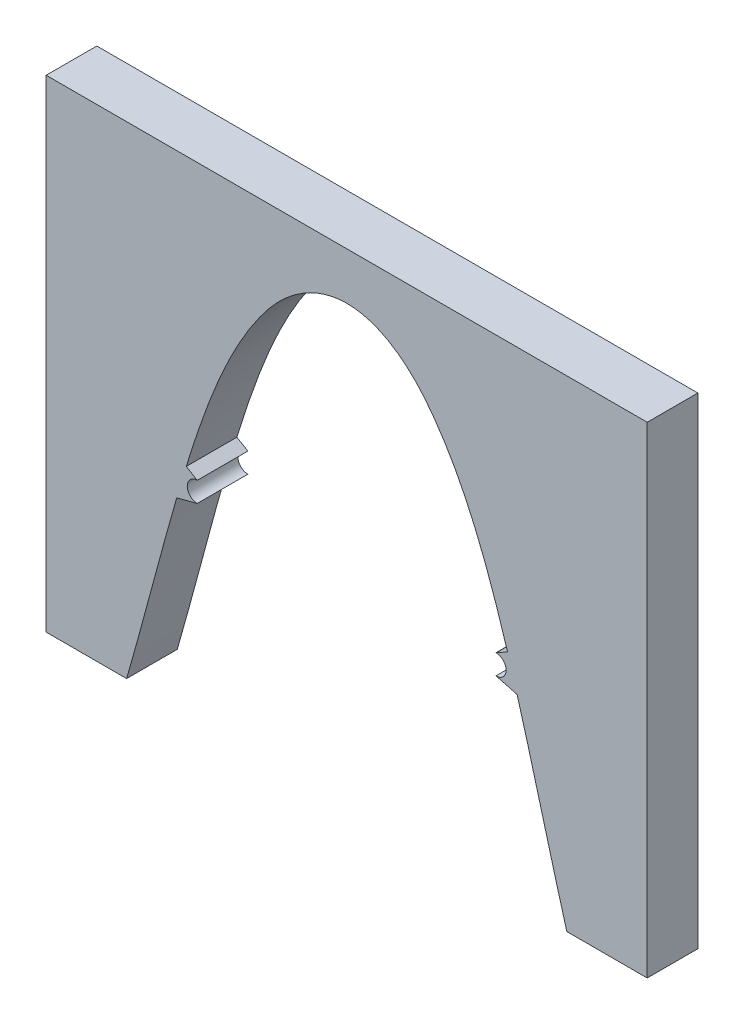
from build123d import *

# Parameters (mm, degrees)
BOSS_EXTRUDE1_DEPTH = 48.006


with BuildPart() as part:
    # Sketch1 → Boss-Extrude1 (new body)
    with BuildSketch(Plane.XY):
        with BuildLine():
            Line((-225.447809165, -199.728491805), (-301.738433253, -199.728491805))
            Line((-301.738433253, -199.728491805), (-301.738433253, 257.593482095))
            Line((-301.738433253, 257.593482095), (268.17262038, 257.593482095))
            Line((268.17262038, 257.593482095), (268.17262038, -198.775273895))
            Line((268.17262038, -198.775273895), (191.97262038, -198.775273895))
            add(Edge.make_bspline(
                [(191.97262038, -198.775273895), (176.395114076, -144.717919568), (162.628696684, -89.958041402), (146.381833133, -33.125288105), (145.596508442, -30.394873062), (144.806285869, -27.666357915)],
                knots=[-0.175685276, -0.175685276, -0.175685276, -0.175685276, 0.0625, 0.0625, 0.074528353, 0.074528353, 0.074528353, 0.074528353], degree=3))
            Line((144.806285869, -27.666357915), (124.993066201, -22.397165799))
            ThreePointArc((124.993066201, -22.397165799), (124.864606243, -22.396297326), (124.73616977, -22.393692067))
            ThreePointArc((124.73616977, -22.393692067), (134.400862059, -12.896168334), (124.73616977, -3.398644601))
            ThreePointArc((124.73616977, -3.398644601), (124.864606243, -3.396039342), (124.993066201, -3.395170869))
            Line((124.993066201, -3.395170869), (135.691858465, 2.892490258))
            add(Edge.make_bspline(
                [(135.691858465, 2.892490258), (135.314696992, 4.116620429), (134.936080504, 5.340186197), (132.368798727, 13.599894472), (130.130676764, 20.616852667), (125.524522045, 34.600376485), (123.157499627, 41.56733402), (115.797446194, 62.367745534), (110.548077039, 76.101765603), (101.84386822, 96.380777425), (98.803508299, 103.086546431), (92.37760033, 116.364185503), (88.991984333, 122.93602921), (81.793802186, 135.914102083), (77.981892113, 142.320585742), (71.869018874, 151.777087043), (69.765373982, 154.903644709), (66.498270777, 159.550177507), (65.389046261, 161.093925459), (63.139466255, 164.154354329), (61.999715438, 165.67035493), (59.688642648, 168.672361294), (58.516582662, 170.157665892), (56.118741461, 173.07723611), (54.894863863, 174.513310302), (51.146947128, 178.749057722), (48.547654076, 181.477234393), (43.125667167, 186.721341125), (40.303191615, 189.237478591), (36.614892879, 192.230444978), (35.869197363, 192.821403706), (34.36104399, 193.987395747), (33.597594293, 194.563112067), (31.290848107, 196.257908313), (29.73009776, 197.345850464), (24.975195611, 200.476791242), (21.708805955, 202.387660075), (16.643768494, 204.951334349), (14.927623421, 205.755045007), (11.435265949, 207.25259756), (9.658083095, 207.946955193), (0.616700415, 211.11100678), (-6.80726538, 212.55901149), (-15.400709246, 212.817467767), (-16.361129064, 212.827100658), (-18.275408627, 212.807502125), (-19.229283176, 212.778493337), (-22.08129591, 212.634925473), (-23.969832382, 212.463879049), (-29.597806643, 211.72933027), (-33.29991159, 210.94619693), (-37.868364024, 209.619128706), (-38.779108314, 209.336382439), (-40.594790871, 208.736732777), (-41.500300425, 208.419508903), (-44.186884114, 207.425196579), (-45.945273264, 206.703343413), (-51.131977033, 204.378066365), (-54.471381822, 202.614119431), (-60.94714312, 198.71963022), (-64.083562314, 196.589201119), (-67.890435469, 193.720972815), (-68.646713056, 193.136501551), (-70.140924932, 191.953327653), (-70.879689492, 191.354019242), (-73.071882243, 189.533784208), (-77.359998234, 185.804199186), (-81.380776129, 181.827144094), (-86.530702533, 176.328982508), (-89.001075507, 173.483084422), (-92.556331251, 169.075103844), (-93.716272996, 167.582502096), (-96.008092078, 164.571319881), (-97.138335587, 163.05122701), (-99.369002363, 159.983437205), (-100.470213051, 158.434560023), (-102.635373146, 155.322818496), (-103.700307999, 153.758645522), (-108.941626474, 145.898561066), (-112.869324351, 139.485640885), (-120.291186221, 126.455819246), (-123.784949756, 119.838729369), (-130.416658057, 106.437133943), (-133.554665544, 99.652657904), (-142.536695847, 79.095973907), (-147.950288071, 65.121244796), (-154.26729307, 47.441111613), (-155.507905268, 43.894362657), (-157.949711034, 36.782317953), (-159.151256343, 33.216131938), (-162.702412424, 22.502511371), (-164.998557993, 15.339085837), (-167.801898158, 6.355762084), (-168.361264212, 4.551240347), (-168.917377957, 2.745760058)],
                knots=[0.119568765, 0.119568765, 0.119568765, 0.119568765, 0.125, 0.125, 0.15625, 0.15625, 0.1875, 0.1875, 0.25, 0.25, 0.28125, 0.28125, 0.3125, 0.3125, 0.34375, 0.34375, 0.359375, 0.359375, 0.3671875, 0.3671875, 0.375, 0.375, 0.3828125, 0.3828125, 0.390625, 0.390625, 0.40625, 0.40625, 0.421875, 0.421875, 0.42578125, 0.42578125, 0.4296875, 0.4296875, 0.4375, 0.4375, 0.453125, 0.453125, 0.4609375, 0.4609375, 0.46875, 0.46875, 0.5, 0.5, 0.50390625, 0.50390625, 0.5078125, 0.5078125, 0.515625, 0.515625, 0.53125, 0.53125, 0.53515625, 0.53515625, 0.5390625, 0.5390625, 0.546875, 0.546875, 0.5625, 0.5625, 0.578125, 0.578125, 0.58203125, 0.58203125, 0.5859375, 0.5859375, 0.59375, 0.609375, 0.609375, 0.625, 0.625, 0.6328125, 0.6328125, 0.640625, 0.640625, 0.6484375, 0.6484375, 0.65625, 0.65625, 0.6875, 0.6875, 0.71875, 0.71875, 0.75, 0.75, 0.8125, 0.8125, 0.828125, 0.828125, 0.84375, 0.84375, 0.875, 0.875, 0.882849734, 0.882849734, 0.882849734, 0.882849734], degree=3))
            Line((-168.917377957, 2.745760058), (-158.468254986, -3.395170869))
            ThreePointArc((-158.468254986, -3.395170869), (-167.969252451, -12.896168334), (-158.468254986, -22.397165799))
            Line((-158.468254986, -22.397165799), (-177.961890902, -27.581366771))
            add(Edge.make_bspline(
                [(-177.961890902, -27.581366771), (-178.686003141, -30.081297074), (-179.405906532, -32.582467849), (-195.783154386, -89.803151614), (-209.643570839, -145.052272814), (-225.447809165, -199.728491805)],
                knots=[0.926684911, 0.926684911, 0.926684911, 0.926684911, 0.9375, 0.9375, 1.173999231, 1.173999231, 1.173999231, 1.173999231], degree=3))
        make_face()
    extrude(amount=BOSS_EXTRUDE1_DEPTH)


solid = part.part
